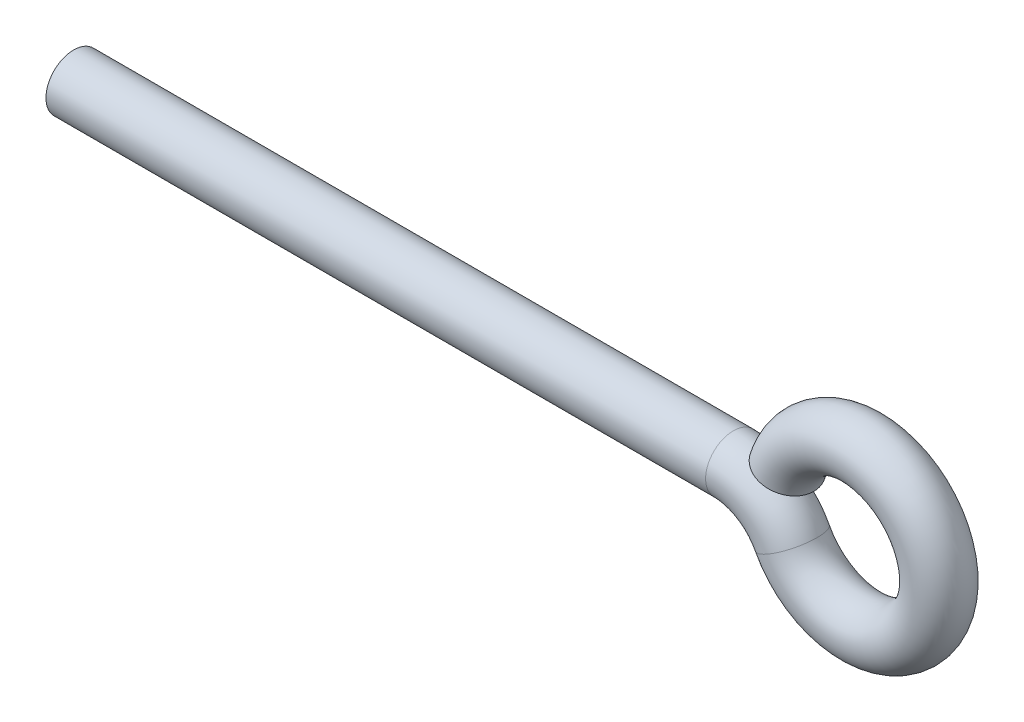
from build123d import *

# Parameters (mm, degrees)
SWEEP1_PROFILE_R = 1.25


with BuildPart() as part:
    # Sweep1: sweep along a path in Schizzo1
    with BuildLine(Plane.XY) as sweep1_path:
        Line((-41.5, 0), (-11.766281297, 0))
        ThreePointArc((-11.766281297, 0), (-10.209657732, -0.435448757), (-9.104920699, -1.615384615))
        ThreePointArc((-9.104920699, -1.615384615), (-2.511986435, 0.289415562), (-9.328697807, 1.08155948))
    # Sweep1 profile (on start of the path) → Sweep1 (sweep)
    with BuildSketch(Plane(origin=(-41.5, 0, 0), x_dir=(0, 0, 1), z_dir=(1, 0, 0))):
        Circle(SWEEP1_PROFILE_R)
    sweep(path=sweep1_path.line)


solid = part.part
